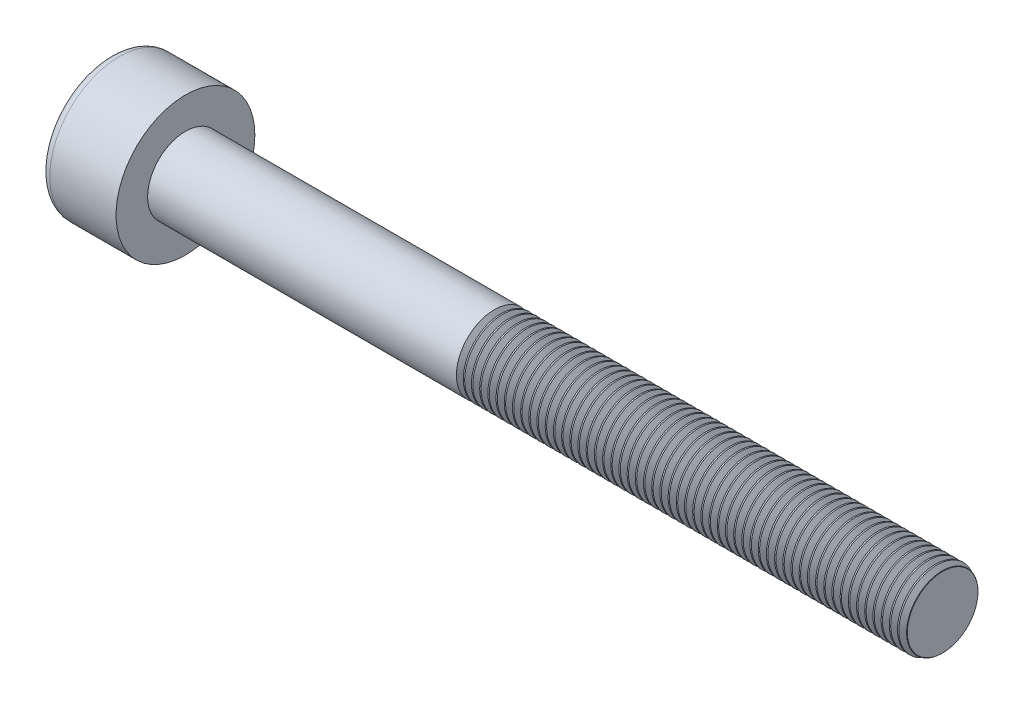
from build123d import *

# Parameters (mm, degrees)
SKETCH1_R           = 2.75
BASEHEAD_DEPTH      = 3
SKETCH2_R           = 1.5
BASEBODY_DEPTH      = 30
HEXAGONSOCKET_DEPTH = 1.3
TOPFILLET_R         = 0.375
CHAMFER1_SIZE       = 0.1
LPATTERN10_COUNT    = 55
LPATTERN10_PITCH    = 0.3246


with BuildPart() as part:
    # Sketch1 → BaseHead (new body)
    with BuildSketch(Plane(origin=(0, 0, 0), x_dir=(0, 0, -1), z_dir=(1, 0, 0))):
        Circle(SKETCH1_R)
    extrude(amount=BASEHEAD_DEPTH)

    # Sketch2 → BaseBody (add)
    with BuildSketch(Plane(origin=(3, 0, 0), x_dir=(0, 0, -1), z_dir=(1, 0, 0))):
        Circle(SKETCH2_R)
    extrude(amount=BASEBODY_DEPTH)

    # Sketch3 → HexagonSocket (cut)
    with BuildSketch(Plane(origin=(0, 0, 0), x_dir=(0, 0, -1), z_dir=(1, 0, 0))):
        Polygon((1.443375673, 0), (0.721687836, 1.25), (-0.721687836, 1.25), (-1.443375673, 0), (-0.721687836, -1.25), (0.721687836, -1.25), align=None)
    extrude(amount=HEXAGONSOCKET_DEPTH, mode=Mode.SUBTRACT)

    # Sketch4 → Cut-Revolve1 (revolve, cut)
    with BuildSketch(Plane(origin=(-4.19613823, 0.75, 0), x_dir=(-1, 0, 0), z_dir=(0, 0, 1))):
        Polygon((-5.49613823, 2), (-6.217826066, 0.75), (-5.49613823, 0.75), align=None)
    revolve(axis=Axis((0.838992387, 0, 0), (-1, 0, 0)), mode=Mode.SUBTRACT)

    # TopFillet
    topfillet_edges = [part.edges().sort_by_distance(p)[0] for p in [
        (0, 0, 2.75),
    ]]
    fillet(topfillet_edges, radius=TOPFILLET_R)

    # Chamfer1
    chamfer1_edges = [part.edges().sort_by_distance(p)[0] for p in [
        (33, 0, 1.5),
    ]]
    chamfer(chamfer1_edges, length=CHAMFER1_SIZE)

    # Sketch5 → Cut-Revolve10 (revolve, cut)
    with BuildSketch(Plane.XY):
        Polygon((32.9, 1.265740128), (33.03525, 1.5), (33.03525, 1.7705), (32.76475, 1.7705), (32.76475, 1.5), align=None)
    cut_revolve10 = revolve(axis=Axis((0, 0, 0), (1, 0, 0)), mode=Mode.SUBTRACT)

    # LPattern10: Cut-Revolve10 ×55
    with Locations(*[(-i * LPATTERN10_PITCH, 0, 0) for i in range(1, LPATTERN10_COUNT)]):
        add(cut_revolve10, mode=Mode.SUBTRACT)


solid = part.part
